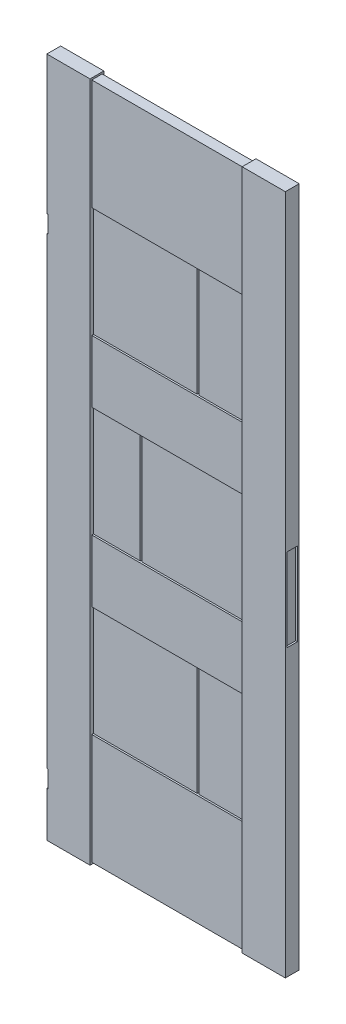
from build123d import *

# Parameters (mm, degrees)
SKETCH3_W           = 690
SKETCH3_H           = 1970
BOSS_EXTRUDE2_DEPTH = 20
SKETCH4_W           = 440
SKETCH4_H           = 1970
CUT_EXTRUDE1_DEPTH  = 5
SKETCH5_W           = 440
SKETCH5_H           = 5
CUT_EXTRUDE2_DEPTH  = 16
SKETCH6_W           = 440
SKETCH6_H           = 320
CUT_EXTRUDE8_DEPTH  = 10
SKETCH7_W           = 5
SKETCH7_H           = 320
CUT_EXTRUDE9_DEPTH  = 5
SKETCH8_W           = 30
SKETCH8_H           = 240
CUT_EXTRUDE10_DEPTH = 5
CUT_EXTRUDE11_DEPTH = 3


with BuildPart() as part:
    # Sketch3 → Boss-Extrude2 (new body)
    with BuildSketch(Plane.XY):
        with Locations((345, -985)):
            Rectangle(SKETCH3_W, SKETCH3_H)
    boss_extrude2 = extrude(amount=-BOSS_EXTRUDE2_DEPTH)

    # Sketch4 → Cut-Extrude1 (cut)
    with BuildSketch(Plane.XY):
        with Locations((345, -985)):
            Rectangle(SKETCH4_W, SKETCH4_H)
    cut_extrude1 = extrude(amount=-CUT_EXTRUDE1_DEPTH, mode=Mode.SUBTRACT)

    # Sketch5 → Cut-Extrude2 (cut, through all)
    with BuildSketch(Plane.XY.offset(-5)):
        with Locations((345, -2.5)):
            Rectangle(SKETCH5_W, SKETCH5_H)
        with Locations((345, -1967.5)):
            Rectangle(SKETCH5_W, SKETCH5_H)
    cut_extrude2 = extrude(amount=-CUT_EXTRUDE2_DEPTH, mode=Mode.SUBTRACT)

    # Sketch6 → Cut-Extrude8 (cut)
    with BuildSketch(Plane.XY):
        with Locations((345, -485)):
            Rectangle(SKETCH6_W, SKETCH6_H)
        with Locations((345, -985)):
            Rectangle(SKETCH6_W, SKETCH6_H)
        with Locations((345, -1485)):
            Rectangle(SKETCH6_W, SKETCH6_H)
    cut_extrude8 = extrude(amount=-CUT_EXTRUDE8_DEPTH, mode=Mode.SUBTRACT)

    # Sketch7 → Cut-Extrude9 (cut)
    with BuildSketch(Plane.XY.offset(-10)):
        with Locations((427.5, -485)):
            Rectangle(SKETCH7_W, SKETCH7_H)
        with Locations((262.5, -985)):
            Rectangle(SKETCH7_W, SKETCH7_H)
        with Locations((427.5, -1485)):
            Rectangle(SKETCH7_W, SKETCH7_H)
    cut_extrude9 = extrude(amount=-CUT_EXTRUDE9_DEPTH, mode=Mode.SUBTRACT)

    # Mirror1: Boss-Extrude2, Cut-Extrude1, Cut-Extrude2, Cut-Extrude8, Cut-Extrude9 across plane
    add(boss_extrude2.mirror(Plane.XY.offset(-20)))
    add(cut_extrude1.mirror(Plane.XY.offset(-20)), mode=Mode.SUBTRACT)
    add(cut_extrude2.mirror(Plane.XY.offset(-20)), mode=Mode.SUBTRACT)
    add(cut_extrude8.mirror(Plane.XY.offset(-20)), mode=Mode.SUBTRACT)
    add(cut_extrude9.mirror(Plane.XY.offset(-20)), mode=Mode.SUBTRACT)

    # Sketch8 → Cut-Extrude10 (cut)
    with BuildSketch(Plane(origin=(690, 0, 0), x_dir=(0, 0, -1), z_dir=(1, 0, 0))):
        with Locations((20, -1025)):
            Rectangle(SKETCH8_W, SKETCH8_H)
    extrude(amount=-CUT_EXTRUDE10_DEPTH, mode=Mode.SUBTRACT)

    # Sketch9 → Cut-Extrude11 (cut)
    with BuildSketch(Plane.ZY):
        with BuildLine():
            Line((-35, -400), (-35, -490))
            ThreePointArc((-35, -490), (-20, -500), (-5, -490))
            Line((-5, -490), (-5, -450))
            Line((-5, -450), (0, -450))
            Line((0, -450), (0, -400))
            Line((0, -400), (-35, -400))
        make_face()
        with BuildLine():
            Line((-35, -1790), (-35, -1880))
            ThreePointArc((-35, -1880), (-20, -1890), (-5, -1880))
            Line((-5, -1880), (-5, -1840))
            Line((-5, -1840), (0, -1840))
            Line((0, -1840), (0, -1790))
            Line((0, -1790), (-35, -1790))
        make_face()
    extrude(amount=-CUT_EXTRUDE11_DEPTH, mode=Mode.SUBTRACT)


solid = part.part
